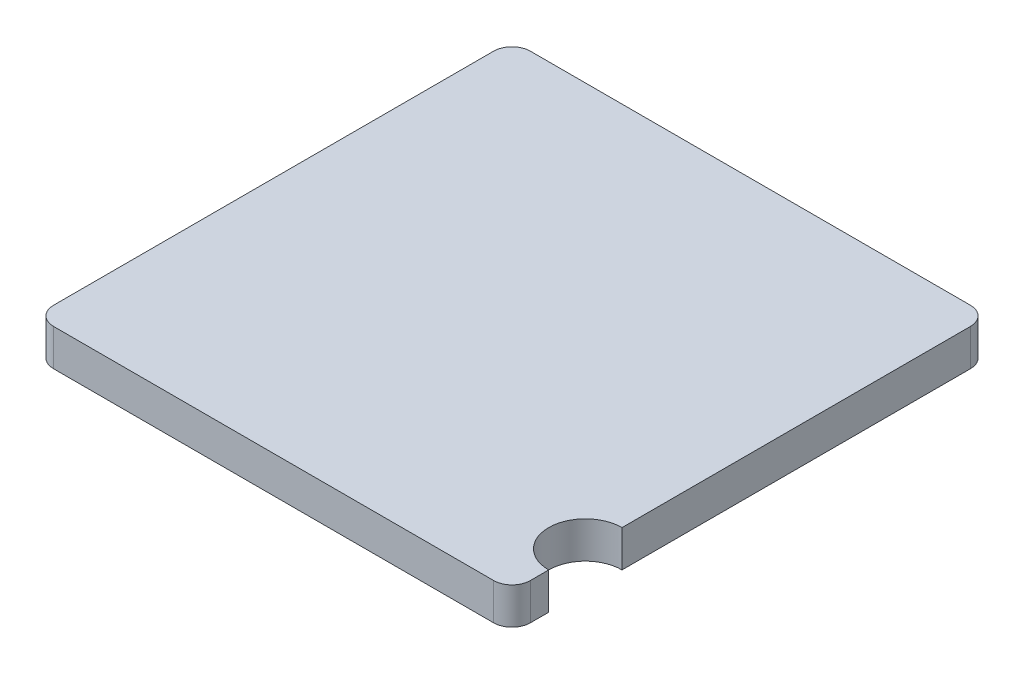
from build123d import *

# Parameters (mm, degrees)
SKETCH1_W           = 2.6
SKETCH1_H           = 2.6
BOSS_EXTRUDE1_DEPTH = 0.2
FILLET1_R           = 0.1
SKETCH3_R           = 0.2
CUT_EXTRUDE1_DEPTH  = 1.2


with BuildPart() as part:
    # Sketch1 → Boss-Extrude1 (new body)
    with BuildSketch(Plane(origin=(0, 0, 0), x_dir=(1, 0, 0), z_dir=(0, 1, 0))):
        Rectangle(SKETCH1_W, SKETCH1_H)
    extrude(amount=BOSS_EXTRUDE1_DEPTH)

    # Fillet1
    fillet1_edges = [part.edges().sort_by_distance(p)[0] for p in [
        (1.3, 0.1, 1.3),
        (-1.3, 0.1, 1.3),
        (-1.3, 0.1, -1.3),
        (1.3, 0.1, -1.3),
    ]]
    fillet(fillet1_edges, radius=FILLET1_R)

    # Sketch3 → Cut-Extrude1 (cut, through all)
    with BuildSketch(Plane.XZ):
        with Locations((1.3, 0.9)):
            Circle(SKETCH3_R)
    extrude(amount=-CUT_EXTRUDE1_DEPTH, mode=Mode.SUBTRACT)


solid = part.part
